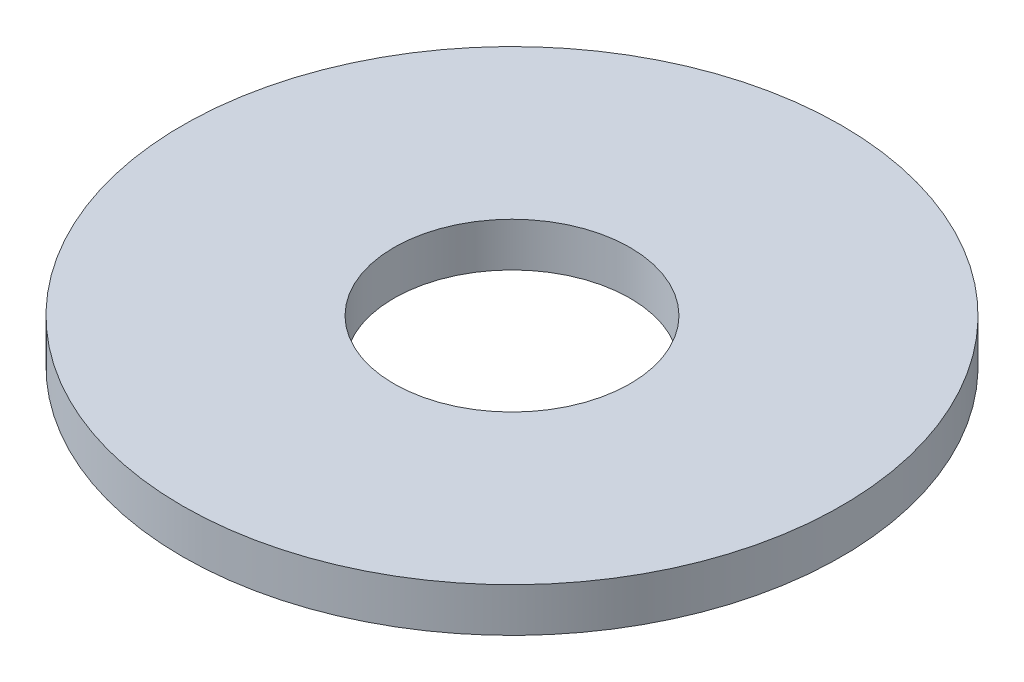
from build123d import *

# Parameters (mm, degrees)
SCHIZZO1_R                   = 6
SCHIZZO1_R_2                 = 2.15
ESTRUSIONE_ESTRUSIONE1_DEPTH = 0.8
SCALE1_SCALE                 = 1.76744


with BuildPart() as part:
    # Schizzo1 → Estrusione-Estrusione1 (new body)
    with BuildSketch(Plane(origin=(0, 0, 0), x_dir=(1, 0, 0), z_dir=(0, 1, 0))):
        Circle(SCHIZZO1_R)
        Circle(SCHIZZO1_R_2, mode=Mode.SUBTRACT)
    extrude(amount=ESTRUSIONE_ESTRUSIONE1_DEPTH)


with BuildPart() as part_1:
    # Scale1: scaled about (0, 0.4, 0)
    add(part.part.scale(SCALE1_SCALE).moved(Location((0, -0.306976, 0))))


solid = part_1.part
